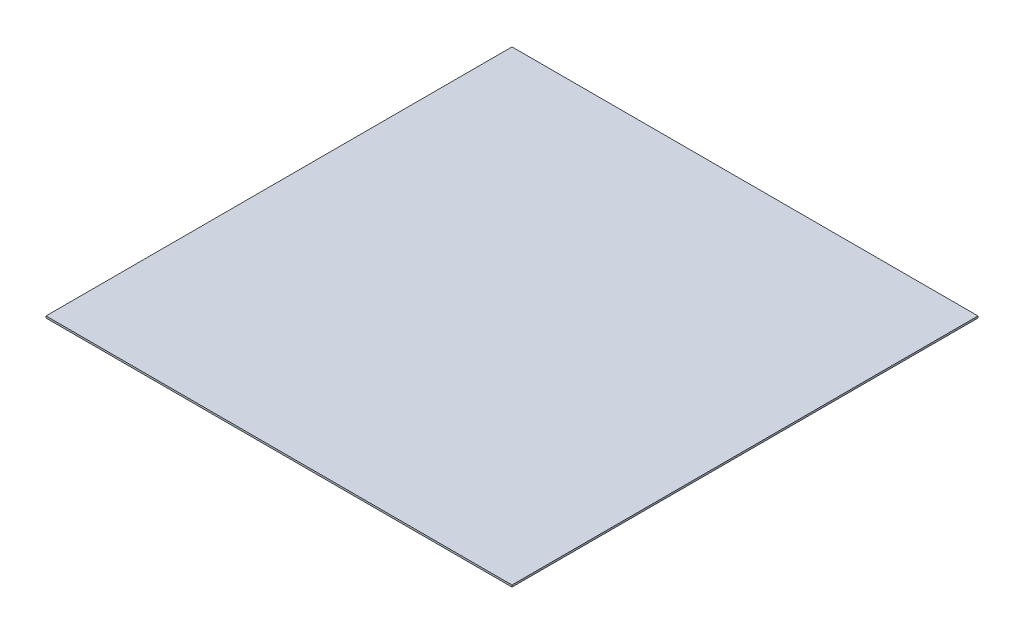
from build123d import *

# Parameters (mm, degrees)
SZKIC1_W                    = 25000
SZKIC1_H                    = 25000
DODANIE_WYCI_GNI_CIE1_DEPTH = 100


with BuildPart() as part:
    # Szkic1 → Dodanie-wyciągnięcie1 (new body)
    with BuildSketch(Plane(origin=(0, 0, 0), x_dir=(1, 0, 0), z_dir=(0, 1, 0))):
        Rectangle(SZKIC1_W, SZKIC1_H)
    extrude(amount=DODANIE_WYCI_GNI_CIE1_DEPTH)


solid = part.part
